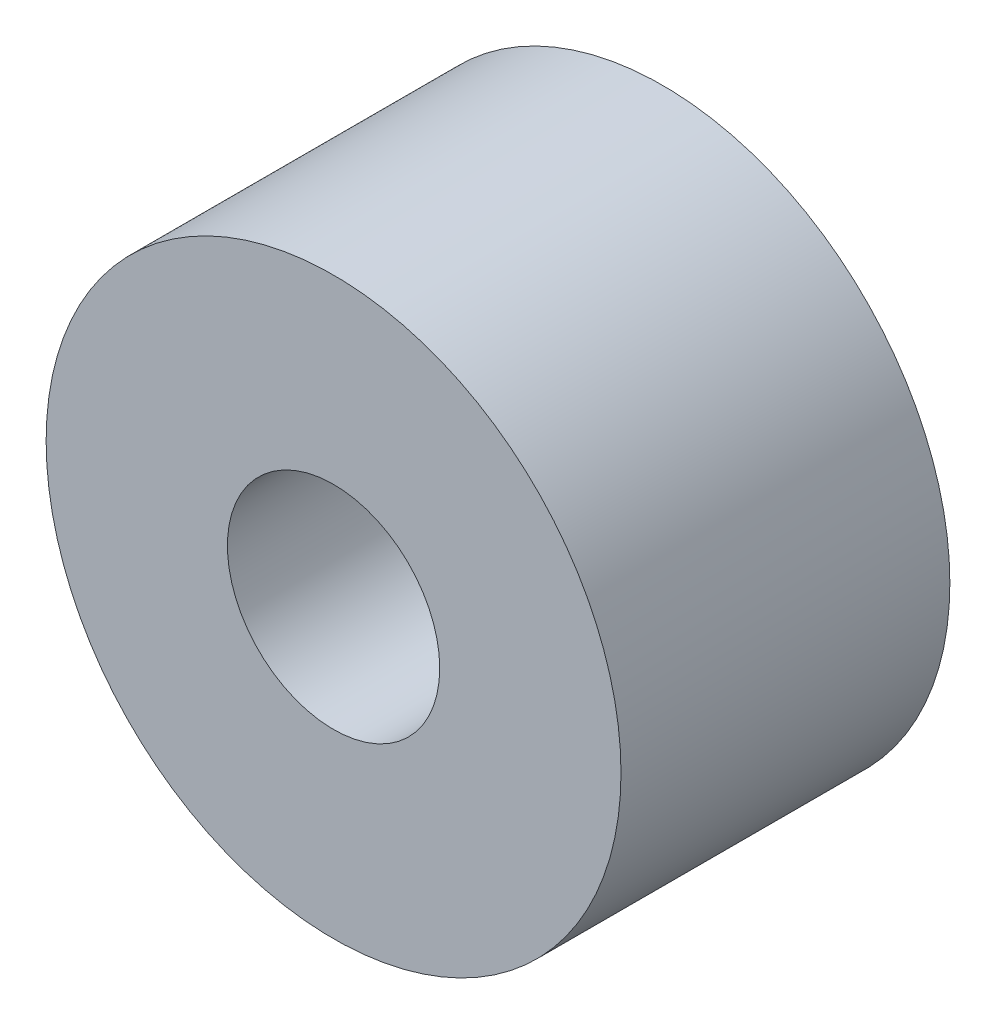
from build123d import *

# Parameters (mm, degrees)
SKETCH1_R           = 5.55
SKETCH1_R_2         = 2.05
BOSS_EXTRUDE1_DEPTH = 6.35


with BuildPart() as part:
    # Sketch1 → Boss-Extrude1 (new body)
    with BuildSketch(Plane.XY):
        Circle(SKETCH1_R)
        Circle(SKETCH1_R_2, mode=Mode.SUBTRACT)
    extrude(amount=BOSS_EXTRUDE1_DEPTH)


solid = part.part
